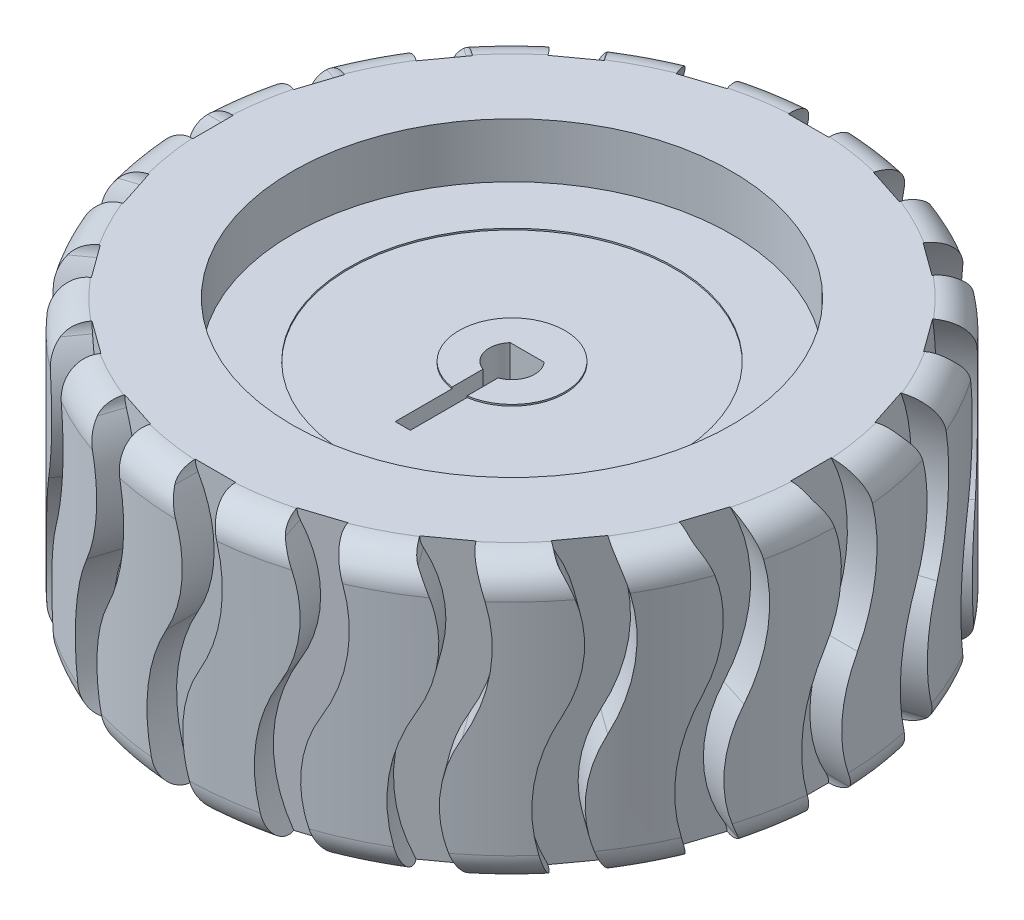
from build123d import *

# Parameters (mm, degrees)
SKETCH1_R           = 21.75
BOSS_EXTRUDE1_DEPTH = 18.5
FILLET1_R           = 2
SKETCH2_R           = 14.5
CUT_EXTRUDE1_DEPTH  = 3.6
CUT_EXTRUDE2_START  = -7.1
SKETCH3_R           = 14.5
CUT_EXTRUDE2_DEPTH  = 7.1
BOSS_EXTRUDE2_DEPTH = 6.5
CIRPATTERN1_COUNT   = 12
CUT_EXTRUDE3_START  = -6
SKETCH5_R           = 12
CUT_EXTRUDE3_DEPTH  = 6
SKETCH6_R           = 4
BOSS_EXTRUDE3_DEPTH = 6
BOSS_EXTRUDE5_DEPTH = 0.75
CIRPATTERN2_COUNT   = 6
CUT_EXTRUDE4_DEPTH  = 33.803734645
SKETCH10_W          = 1
SKETCH10_H          = 8.21
CUT_EXTRUDE5_DEPTH  = 35.177990057
SKETCH11_R          = 10.75
SKETCH11_R_2        = 3.5
CUT_EXTRUDE6_DEPTH  = 0.1
CUT_EXTRUDE8_DEPTH  = 2.1
CIRPATTERN3_COUNT   = 20


with BuildPart() as part:
    # Sketch1 → Boss-Extrude1 (new body)
    with BuildSketch(Plane(origin=(0, 0, 0), x_dir=(1, 0, 0), z_dir=(0, 1, 0))):
        Circle(SKETCH1_R)
    extrude(amount=BOSS_EXTRUDE1_DEPTH)

    # Fillet1
    fillet1_edges = [part.edges().sort_by_distance(p)[0] for p in [
        (-21.75, 0, 0),
        (-21.75, 18.5, 0),
    ]]
    fillet(fillet1_edges, radius=FILLET1_R)

    # Sketch2 → Cut-Extrude1 (cut)
    with BuildSketch(Plane(origin=(0, 18.5, 0), x_dir=(1, 0, 0), z_dir=(0, 1, 0))):
        Circle(SKETCH2_R)
    extrude(amount=-CUT_EXTRUDE1_DEPTH, mode=Mode.SUBTRACT)

    # Sketch3 → Cut-Extrude2 (cut)
    with BuildSketch(Plane.XZ.offset(CUT_EXTRUDE2_START)):
        Circle(SKETCH3_R)
    extrude(amount=CUT_EXTRUDE2_DEPTH, mode=Mode.SUBTRACT)

    # Sketch4 → Boss-Extrude2 (add)
    with BuildSketch(Plane.XZ.offset(-7.1)):
        with BuildLine():
            Line((-1.303448276, 11.928999228), (-1.575, 14.414207401))
            ThreePointArc((-1.575, 14.414207401), (0, 14.5), (1.575, 14.414207401))
            Line((1.575, 14.414207401), (1.303448276, 11.928999228))
            ThreePointArc((1.303448276, 11.928999228), (0, 12), (-1.303448276, 11.928999228))
        make_face()
    boss_extrude2 = extrude(amount=BOSS_EXTRUDE2_DEPTH)

    # CirPattern1: Boss-Extrude2 ×12 about axis
    cirpattern1_axis = Axis((0, 0, 0), (0, -1, 0))
    for i in range(1, CIRPATTERN1_COUNT):
        add(boss_extrude2.rotate(cirpattern1_axis, i * 360 / CIRPATTERN1_COUNT))

    # Sketch5 → Cut-Extrude3 (cut)
    with BuildSketch(Plane.XZ.offset(-7.1).offset(CUT_EXTRUDE3_START)):
        Circle(SKETCH5_R)
    extrude(amount=CUT_EXTRUDE3_DEPTH, mode=Mode.SUBTRACT)

    # Sketch6 → Boss-Extrude3 (add)
    with BuildSketch(Plane.XZ.offset(-13.1)):
        Circle(SKETCH6_R)
    extrude(amount=BOSS_EXTRUDE3_DEPTH)

    # Sketch8 → Boss-Extrude5 (add, symmetric)
    with BuildSketch(Plane.XY):
        Polygon((3.5, 9.1), (3.5, 13.1), (12.5, 13.1), (12.5, 11.1), align=None)
    boss_extrude5 = extrude(amount=BOSS_EXTRUDE5_DEPTH, both=True)

    # CirPattern2: Boss-Extrude5 ×6 about axis
    cirpattern2_axis = Axis((0, 0, 0), (0, -1, 0))
    for i in range(1, CIRPATTERN2_COUNT):
        add(boss_extrude5.rotate(cirpattern2_axis, i * 360 / CIRPATTERN2_COUNT))

    # Sketch9 → Cut-Extrude4 (cut, through all)
    with BuildSketch(Plane.XZ.offset(-7.1)):
        with BuildLine():
            Line((-1.118033989, -1), (1.118033989, -1))
            ThreePointArc((1.118033989, -1), (0, 1.5), (-1.118033989, -1))
        make_face()
    extrude(amount=-CUT_EXTRUDE4_DEPTH, mode=Mode.SUBTRACT)

    # Sketch10 → Cut-Extrude5 (cut, through all)
    with BuildSketch(Plane(origin=(0, 14.9, 0), x_dir=(1, 0, 0), z_dir=(0, 1, 0))):
        with Locations((0, -3.105)):
            Rectangle(SKETCH10_W, SKETCH10_H)
    extrude(amount=-CUT_EXTRUDE5_DEPTH, mode=Mode.SUBTRACT)

    # Sketch11 → Cut-Extrude6 (cut)
    with BuildSketch(Plane(origin=(0, 14.9, 0), x_dir=(1, 0, 0), z_dir=(0, 1, 0))):
        Circle(SKETCH11_R)
        Circle(SKETCH11_R_2, mode=Mode.SUBTRACT)
    extrude(amount=-CUT_EXTRUDE6_DEPTH, mode=Mode.SUBTRACT)

    # Sketch12 → Cut-Extrude8 (cut)
    with BuildSketch(Plane(origin=(21.75, 0, 0), x_dir=(0, 0, -1), z_dir=(1, 0, 0))):
        with BuildLine():
            ThreePointArc((1.082531755, 8.625), (0.010734985, 4.625), (1.082531755, 0.625))
            ThreePointArc((1.082531755, 0.625), (0.625, -1.082531755), (-1.082531755, -0.625))
            ThreePointArc((-1.082531755, -0.625), (-2.489265015, 4.625), (-1.082531755, 9.875))
            ThreePointArc((-1.082531755, 9.875), (-0.010734985, 13.875), (-1.082531755, 17.875))
            ThreePointArc((-1.082531755, 17.875), (-0.625, 19.582531755), (1.082531755, 19.125))
            ThreePointArc((1.082531755, 19.125), (2.489265015, 13.875), (1.082531755, 8.625))
        make_face()
    cut_extrude8 = extrude(amount=-CUT_EXTRUDE8_DEPTH, mode=Mode.SUBTRACT)

    # CirPattern3: Cut-Extrude8 ×20 about axis
    cirpattern3_axis = Axis((0, 7.1, 0), (0, -1, 0))
    for i in range(1, CIRPATTERN3_COUNT):
        add(cut_extrude8.rotate(cirpattern3_axis, i * 360 / CIRPATTERN3_COUNT), mode=Mode.SUBTRACT)


solid = part.part
